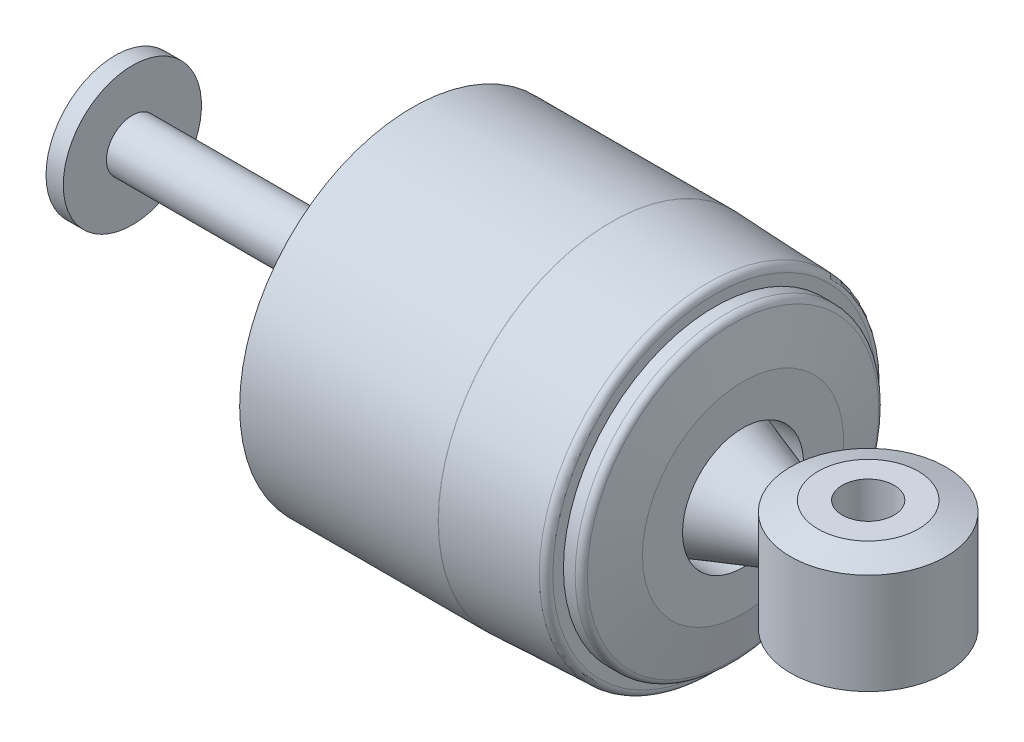
from build123d import *
from OCP.BRepFilletAPI import BRepFilletAPI_MakeChamfer

# Parameters (mm, degrees)
SKETCH2_R           = 14.2875
SKETCH2_R_2         = 4.7625
BOSS_EXTRUDE1_DEPTH = 11.1125
CHAMFER1_SIZE       = 5.08
CHAMFER1_SIZE2      = 1.84896879
FILLET1_R           = 1.27


with BuildPart() as part:
    # Sketch1 → Revolve1 (revolve)
    with BuildSketch(Plane(origin=(0, 0, 0), x_dir=(1, 0, 0), z_dir=(0, 1, 0)), mode=Mode.PRIVATE) as revolve1_sk:
        Polygon((-68.007276158, 20.214239498), (-68.007276158, 7.514239498), (57.849723842, 7.514239498), (57.849723842, 13.229239498), (41.847723842, 18.626739498), (41.847723842, 12.276739498), (-64.832276158, 12.276739498), (-64.832276158, 20.214239498), align=None)
    revolve(revolve1_sk.sketch.rotate(Axis((-68.007276158, 0, -7.514239498), (1, 0, 0)), 180), axis=Axis((-68.007276158, 0, -7.514239498), (1, 0, 0)))

    # Sketch3 → Revolve2 (revolve)
    with BuildSketch(Plane(origin=(0, 0, 0), x_dir=(1, 0, 0), z_dir=(0, 1, 0)), mode=Mode.PRIVATE) as revolve2_sk:
        Polygon((41.847723842, 12.276739498), (41.847723842, 18.626739498), (47.403973842, 18.626739498), (47.403973842, 25.992739498), (45.358376756, 35.295489498), (42.183376756, 35.295489498), (42.183376756, 38.470489498), (23.149920398, 39.264239498), (-13.362579602, 39.264239498), (-13.362579602, 38.470489498), (23.133376756, 38.470489498), (39.643376756, 37.781974903), (41.053973842, 27.778209953), (41.053973842, 12.276739498), align=None)
        Polygon((41.053973842, 2.751739498), (41.847723842, 2.751739498), (41.847723842, -3.598260502), (47.403973842, -3.598260502), (47.403973842, -10.964260502), (45.358376756, -20.267010502), (42.183376756, -20.267010502), (42.183376756, -23.442010502), (23.149920398, -24.235760502), (-13.362579602, -24.235760502), (-13.362579602, -23.442010502), (23.133376756, -23.442010502), (39.643376756, -22.753495907), (41.053973842, -12.749730957), align=None)
    revolve(revolve2_sk.sketch.rotate(Axis((-68.086651194, 0, -7.514239498), (1, 0, 0)), 180), axis=Axis((-68.086651194, 0, -7.514239498), (1, 0, 0)))

    # Fillet1
    fillet1_edges = [part.edges().sort_by_distance(p)[0] for p in [
        (45.358376756, 0, -35.295489498),
        (42.183376756, 0, -38.470489498),
        (23.149920398, 0, -39.264239498),
    ]]
    fillet(fillet1_edges, radius=FILLET1_R)


with BuildPart() as body_2:
    # Sketch2 → Boss-Extrude1 (new, symmetric)
    with BuildSketch(Plane(origin=(0, 0, 0), x_dir=(1, 0, 0), z_dir=(0, 1, 0))):
        with Locations(Location((70.422723842, 7.514239498, 0), (0, 0, 270))):
            Circle(SKETCH2_R)
        with Locations(Location((70.422723842, 7.514239498, 0), (0, 0, 270))):
            Circle(SKETCH2_R_2, mode=Mode.SUBTRACT)
    extrude(amount=BOSS_EXTRUDE1_DEPTH, both=True)

    # Chamfer1: one chamfer whose edges measure the first distance from different faces: ONE call of the kernel's chamfer builder (chamfer() names one face for all edges)
    chamfer1_edges_1 = [body_2.edges().sort_by_distance(p)[0] for p in [
        (70.422723842, -11.1125, -21.801739498),
    ]]
    chamfer1_side_1 = [body_2.faces().sort_by_distance(p)[0] for p in [
        (70.422723842, -11.1125, -21.397627972),
    ]]
    chamfer1_edges_2 = [body_2.edges().sort_by_distance(p)[0] for p in [
        (70.422723842, 11.1125, -21.801739498),
    ]]
    chamfer1_side_2 = [body_2.faces().sort_by_distance(p)[0] for p in [
        (70.422723842, 11.1125, -21.397627972),
    ]]
    chamfer1 = BRepFilletAPI_MakeChamfer(body_2.part.solid().wrapped)
    for e in chamfer1_edges_1:
        chamfer1.Add(CHAMFER1_SIZE, CHAMFER1_SIZE2, e.wrapped, chamfer1_side_1[0].wrapped)  # the first distance lies on this face
    for e in chamfer1_edges_2:
        chamfer1.Add(CHAMFER1_SIZE, CHAMFER1_SIZE2, e.wrapped, chamfer1_side_2[0].wrapped)  # the first distance lies on this face
    add(Compound.cast(chamfer1.Shape()), mode=Mode.REPLACE)


solid = Compound([part.part, body_2.part])
